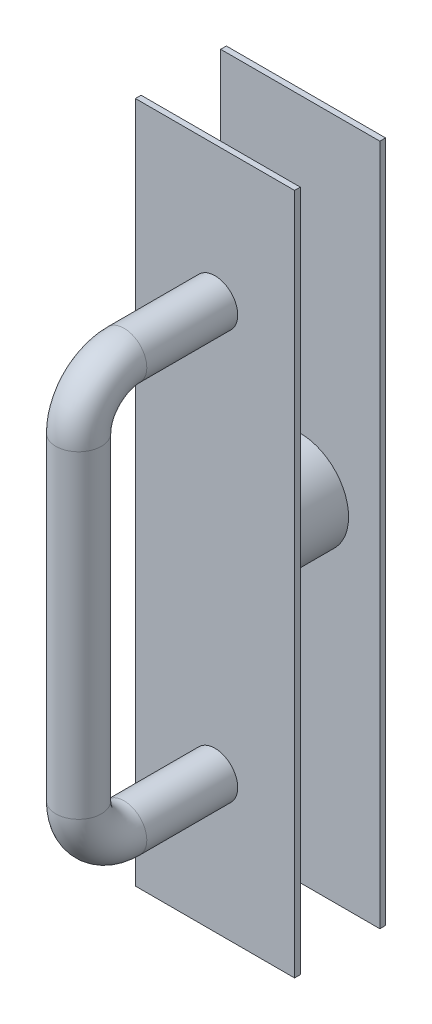
from build123d import *

# Parameters (mm, degrees)
SKETCH1_R           = 26.9875
BOSS_EXTRUDE1_DEPTH = 44.45
SKETCH2_W           = 88.9
SKETCH2_H           = 381
BOSS_EXTRUDE2_DEPTH = 3.175
SKETCH3_R           = 12.7
SKETCH6_W           = 88.9
SKETCH6_H           = 381
BOSS_EXTRUDE3_DEPTH = 3.175


with BuildPart() as part:
    # Sketch1 → Boss-Extrude1 (new body)
    with BuildSketch(Plane.XY):
        Circle(SKETCH1_R)
    extrude(amount=-BOSS_EXTRUDE1_DEPTH)

    # Sketch2 → Boss-Extrude2 (add)
    with BuildSketch(Plane.XY):
        Rectangle(SKETCH2_W, SKETCH2_H)
    extrude(amount=BOSS_EXTRUDE2_DEPTH)

    # Sweep1: sweep along a path in Sketch5
    with BuildLine(Plane(origin=(0, 0, 0), x_dir=(0, 0, -1), z_dir=(1, 0, 0))) as sweep1_path:
        Line((-3.175, -114.3), (-53.975, -114.3))
        ThreePointArc((-53.975, -114.3), (-71.935512242, -106.860512242), (-79.375, -88.9))
        Line((-79.375, -88.9), (-79.375, 88.9))
        ThreePointArc((-79.375, 88.9), (-71.935512242, 106.860512242), (-53.975, 114.3))
        Line((-53.975, 114.3), (-3.175, 114.3))
    # Sketch3 → Sweep1 (sweep)
    with BuildSketch(Plane.XY.offset(3.175)):
        with Locations((0, -114.3)):
            Circle(SKETCH3_R)
    sweep(path=sweep1_path.line)

    # Sketch6 → Boss-Extrude3 (add)
    with BuildSketch(Plane(origin=(0, 0, -44.45), x_dir=(-1, 0, 0), z_dir=(0, 0, -1))):
        Rectangle(SKETCH6_W, SKETCH6_H)
    extrude(amount=BOSS_EXTRUDE3_DEPTH)


solid = part.part
